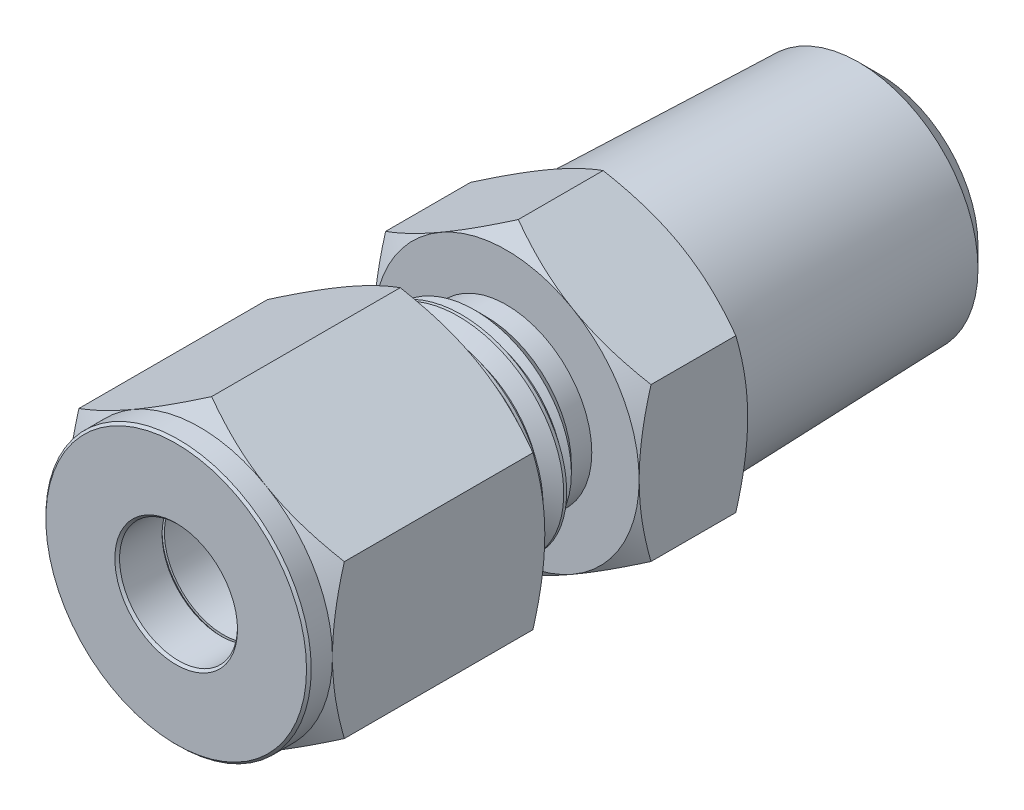
from build123d import *

# Parameters (mm, degrees)
BOSS_EXTRUDE1_DEPTH    = 12.7
CHAMFER1_SIZE          = 0.127
SKETCH4_W              = 16.256
SKETCH4_H              = 5.55625
CUT_SWEEP1_PITCH       = 1.27
CUT_SWEEP1_HEIGHT      = 17.526
CUT_SWEEP1_RADIUS      = 5.55625
CUT_SWEEP1_START_ANGLE = 90
BOSS_EXTRUDE2_DEPTH    = 5.842


with BuildPart() as part:
    # Sketch2 → Boss-Extrude1 (new body)
    with BuildSketch(Plane.XY):
        Polygon((0, 8.248891971), (-7.14375, 4.124445986), (-7.14375, -4.124445986), (0, -8.248891971), (7.14375, -4.124445986), (7.14375, 4.124445986), align=None)
    extrude(amount=-BOSS_EXTRUDE1_DEPTH)

    # Sketch3 → Cut-Revolve1 (revolve, cut)
    with BuildSketch(Plane(origin=(0, 0, 0), x_dir=(0, 0, -1), z_dir=(1, 0, 0)), mode=Mode.PRIVATE) as cut_revolve1_sk:
        Polygon((0, 8.248891971), (0, 7.14375), (1.27, 7.14375), (1.908054014, 8.248891971), (12.061945986, 8.248891971), (12.7, 7.14375), (12.7, 8.248891971), (12.7, 9.354033942), (0, 9.354033942), align=None)
        Polygon((0, 3.175), (0, 0), (12.7, 0), (12.7, 5.55625), (5.08, 5.55625), (5.08, 4.92125), (2.54, 4.92125), (2.54, 4.28625), (2.54, 3.175), align=None)
    revolve(cut_revolve1_sk.sketch.rotate(Axis((0, 0, 0), (0, 0, -1)), 90), axis=Axis((0, 0, 0), (0, 0, -1)), mode=Mode.SUBTRACT)

    # Chamfer1
    chamfer1_edges = [part.edges().sort_by_distance(p)[0] for p in [
        (-7.14375, 0, 0),
        (-3.175, 0, -2.54),
        (-3.175, 0, 0),
    ]]
    chamfer(chamfer1_edges, length=CHAMFER1_SIZE)


with BuildPart() as body_2:
    # Sketch4 → Revolve1 (revolve)
    with BuildSketch(Plane(origin=(0, 0, 0), x_dir=(0, 0, -1), z_dir=(1, 0, 0)), mode=Mode.PRIVATE) as revolve1_sk:
        with Locations((15.494, 2.778125)):
            Rectangle(SKETCH4_W, SKETCH4_H)
    revolve(revolve1_sk.sketch.rotate(Axis((0, 0, -23.622), (0, 0, 1)), 270), axis=Axis((0, 0, -23.622), (0, 0, 1)))

    # Cut-Sweep1: sweep along a helix
    with BuildLine() as cut_sweep1_path:
        add(Helix(CUT_SWEEP1_PITCH, CUT_SWEEP1_HEIGHT, CUT_SWEEP1_RADIUS, center=(0, 0, -7.366), direction=(0, 0, -1), mode=Mode.PRIVATE).rotate(Axis((0, 0, -7.366), (0, 0, -1)), CUT_SWEEP1_START_ANGLE))
    with BuildLine() as cut_sweep1_axis:
        Line((0, 0, -7.366), (0, 0, -24.892))
    # Sketch6 → Cut-Sweep1 (sweep, cut)
    with BuildSketch(Plane(origin=(0, 0, 0), x_dir=(0, 0, -1), z_dir=(1, 0, 0))):
        Polygon((6.731, 4.731360803), (6.2150625, 5.624990766), (7.4056875, 5.624990766), (6.88975, 4.731360803), align=None)
    sweep(path=cut_sweep1_path.line, binormal=cut_sweep1_axis.edges()[0], mode=Mode.SUBTRACT)

    # Sketch7 → Boss-Extrude2 (add)
    with BuildSketch(Plane(origin=(0, 0, -23.622), x_dir=(-1, 0, 0), z_dir=(0, 0, -1))):
        Polygon((0, 8.248891971), (-7.14375, 4.124445986), (-7.14375, -4.124445986), (0, -8.248891971), (7.14375, -4.124445986), (7.14375, 4.124445986), align=None)
    extrude(amount=-BOSS_EXTRUDE2_DEPTH)

    # Sketch8 → Cut-Revolve2 (revolve, cut)
    with BuildSketch(Plane(origin=(0, 0, 0), x_dir=(0, 0, -1), z_dir=(1, 0, 0)), mode=Mode.PRIVATE) as cut_revolve2_sk:
        Polygon((7.366, 5.693731533), (7.366, 4.59387927), (8.465852263, 5.693731533), align=None)
        Polygon((17.78, 5.693731533), (15.580295474, 5.693731533), (16.680147737, 4.59387927), (17.78, 4.59387927), align=None)
        Polygon((17.78, 7.14375), (18.418054014, 8.248891971), (22.983945986, 8.248891971), (23.622, 7.14375), (23.622, 8.248891971), (23.622, 9.354033942), (17.78, 9.354033942), (17.78, 8.248891971), align=None)
        Polygon((15.24, 2.3749), (23.622, 2.3749), (23.622, 0), (7.366, 0), (7.366, 4.044817708), (11.249837209, 3.175), (15.24, 3.175), align=None)
    revolve(cut_revolve2_sk.sketch.rotate(Axis((0, 0, 0), (0, 0, -1)), 90), axis=Axis((0, 0, 0), (0, 0, -1)), mode=Mode.SUBTRACT)


with BuildPart() as body_3:
    # Sketch9 → Revolve2 (revolve)
    with BuildSketch(Plane(origin=(0, 0, 0), x_dir=(0, 0, -1), z_dir=(1, 0, 0)), mode=Mode.PRIVATE) as revolve2_sk:
        Polygon((4.445, 4.699), (4.445, 3.8608), (5.1308, 3.175), (9.3218, 3.175), (9.3218, 3.6068), align=None)
    revolve(revolve2_sk.sketch.rotate(Axis((0, 0, 0), (0, 0, -1)), 90), axis=Axis((0, 0, 0), (0, 0, -1)))


with BuildPart() as body_4:
    # Sketch10 → Revolve3 (revolve)
    with BuildSketch(Plane(origin=(0, 0, 0), x_dir=(0, 0, -1), z_dir=(1, 0, 0)), mode=Mode.PRIVATE) as revolve3_sk:
        Polygon((2.54, 4.6609), (3.556, 4.6609), (3.556, 3.8608), (4.445, 3.8608), (5.1308, 3.175), (2.54, 3.175), align=None)
    revolve(revolve3_sk.sketch.rotate(Axis((0, 0, 0), (0, 0, -1)), 90), axis=Axis((0, 0, 0), (0, 0, -1)))


with BuildPart() as body_5:
    # Sketch11 → Revolve4 (revolve)
    with BuildSketch(Plane(origin=(0, 0, 0), x_dir=(0, 0, -1), z_dir=(1, 0, 0)), mode=Mode.PRIVATE) as revolve4_sk:
        Polygon((22.74316, 0), (37.846, 0), (37.846, 6.38777167), (22.74316, 6.858), align=None)
    revolve(revolve4_sk.sketch.rotate(Axis((0, 0, -22.74316), (0, 0, -1)), 90), axis=Axis((0, 0, -22.74316), (0, 0, -1)))


with BuildPart() as body_2_1:
    add(body_2.part)

    # Combine1: union body 5
    add(body_5.part)

    # Sketch14 → Cut-Revolve4 (revolve, cut)
    with BuildSketch(Plane(origin=(0, 0, 0), x_dir=(0, 0, -1), z_dir=(1, 0, 0)), mode=Mode.PRIVATE) as cut_revolve4_sk:
        Polygon((37.846, 5.318470859), (36.62394193, 6.540528929), (37.846, 6.540528929), align=None)
        Polygon((37.846, 4.6228), (22.74316, 4.6228), (19.96550153, 0), (37.846, 0), align=None)
    revolve(cut_revolve4_sk.sketch.rotate(Axis((0, 0, 0), (0, 0, -1)), 90), axis=Axis((0, 0, 0), (0, 0, -1)), mode=Mode.SUBTRACT)


solid = Compound([part.part, body_3.part, body_4.part, body_2_1.part])
